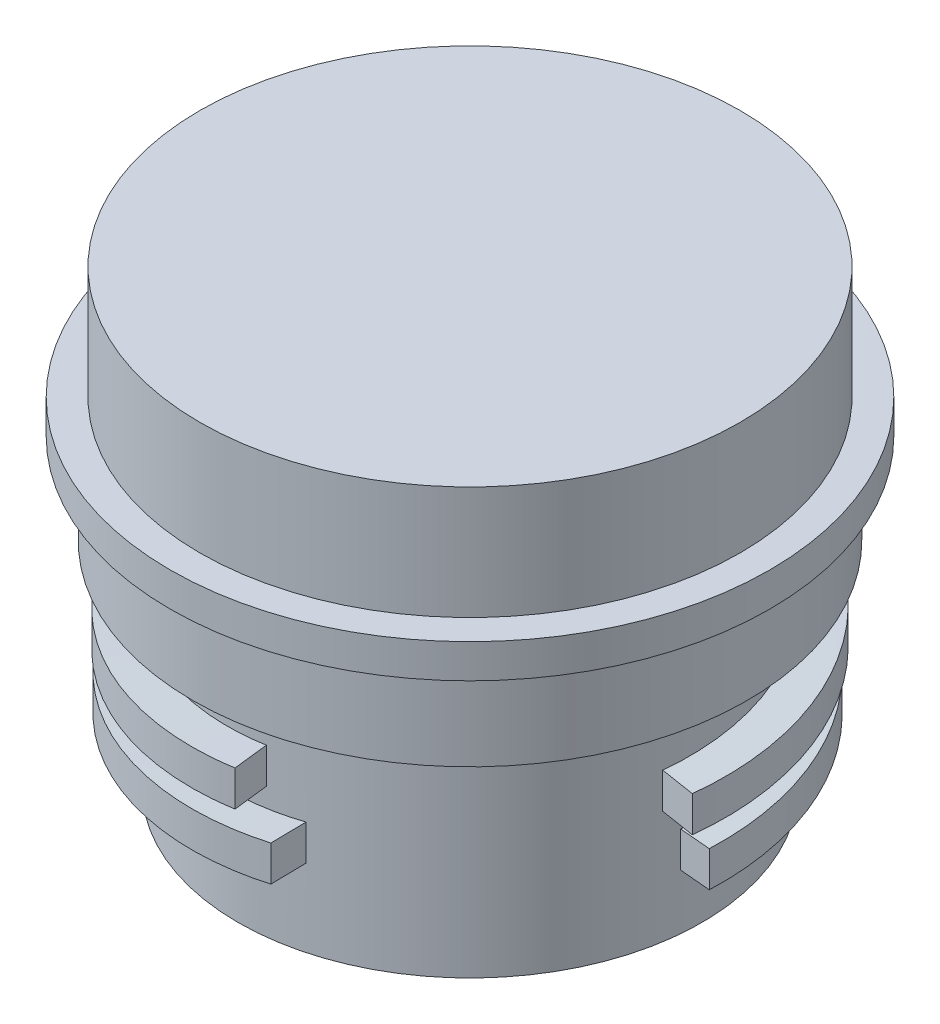
from build123d import *

# Parameters (mm, degrees)
SKETCH1_R           = 20.5
BOSS_EXTRUDE1_DEPTH = 19
SKETCH2_R           = 24.5
BOSS_EXTRUDE2_DEPTH = 8
SKETCH3_R           = 26.5
BOSS_EXTRUDE3_DEPTH = 3
SKETCH4_R           = 23.886443451
BOSS_EXTRUDE4_DEPTH = 10
SWEEP1_PITCH        = 6.35
SWEEP1_HEIGHT       = 1.9685
SWEEP1_RADIUS       = 20.5
SWEEP1_START_ANGLE  = -105
SKETCH10_W          = 6.049698943
SKETCH10_H          = 3.15
SWEEP2_PITCH        = 6.35
SWEEP2_HEIGHT       = 2.2225
SWEEP2_RADIUS       = 20.5
SWEEP2_START_ANGLE  = -111
SKETCH11_W          = 5.521256515
SKETCH11_H          = 3.15
SWEEP3_PITCH        = 6.35
SWEEP3_HEIGHT       = 2.2225
SWEEP3_RADIUS       = 20.5
SWEEP3_START_ANGLE  = 84.999942704
SKETCH18_W          = 6.3
SKETCH18_H          = 3.15
SWEEP4_PITCH        = 6.35
SWEEP4_HEIGHT       = 1.9685
SWEEP4_RADIUS       = 20.5
SWEEP4_START_ANGLE  = 80.999942704
SKETCH19_W          = 6.3
SKETCH19_H          = 3.15


with BuildPart() as part:
    # Sketch1 → Boss-Extrude1 (new body)
    with BuildSketch(Plane(origin=(0, 0, 0), x_dir=(1, 0, 0), z_dir=(0, 1, 0))):
        Circle(SKETCH1_R)
    extrude(amount=BOSS_EXTRUDE1_DEPTH)

    # Sketch2 → Boss-Extrude2 (add)
    with BuildSketch(Plane(origin=(0, 19, 0), x_dir=(1, 0, 0), z_dir=(0, 1, 0))):
        Circle(SKETCH2_R)
    extrude(amount=BOSS_EXTRUDE2_DEPTH)

    # Sketch3 → Boss-Extrude3 (add)
    with BuildSketch(Plane(origin=(0, 27, 0), x_dir=(1, 0, 0), z_dir=(0, 1, 0))):
        Circle(SKETCH3_R)
    extrude(amount=BOSS_EXTRUDE3_DEPTH)

    # Sketch4 → Boss-Extrude4 (add)
    with BuildSketch(Plane(origin=(0, 30, 0), x_dir=(1, 0, 0), z_dir=(0, 1, 0))):
        Circle(SKETCH4_R)
    extrude(amount=BOSS_EXTRUDE4_DEPTH)

    # Sweep1: sweep along a helix
    with BuildLine() as sweep1_path:
        add(Helix(SWEEP1_PITCH, SWEEP1_HEIGHT, SWEEP1_RADIUS, center=(0, 11.25, 0), direction=(0, 1, 0), mode=Mode.PRIVATE).rotate(Axis((0, 11.25, 0), (0, 1, 0)), SWEEP1_START_ANGLE))
    # Sketch10 → Sweep1 (sweep)
    with BuildSketch(Plane.XY):
        with Locations((-20.625150529, 11.420617779)):
            Rectangle(SKETCH10_W, SKETCH10_H)
    sweep(path=sweep1_path.line, is_frenet=True)

    # Sweep2: sweep along a helix
    with BuildLine() as sweep2_path:
        add(Helix(SWEEP2_PITCH, SWEEP2_HEIGHT, SWEEP2_RADIUS, center=(0, 6.25, 0), direction=(0, 1, 0), mode=Mode.PRIVATE).rotate(Axis((0, 6.25, 0), (0, 1, 0)), SWEEP2_START_ANGLE))
    # Sketch11 → Sweep2 (sweep)
    with BuildSketch(Plane.XY.offset(5)):
        with Locations((-20.28419045, 6.826925212)):
            Rectangle(SKETCH11_W, SKETCH11_H)
    sweep(path=sweep2_path.line, is_frenet=True)

    # Sweep3: sweep along a helix
    with BuildLine() as sweep3_path:
        add(Helix(SWEEP3_PITCH, SWEEP3_HEIGHT, SWEEP3_RADIUS, center=(0, 6.25, 0), direction=(0, 1, 0), mode=Mode.PRIVATE).rotate(Axis((0, 6.25, 0), (0, 1, 0)), SWEEP3_START_ANGLE))
    # Sketch18 → Sweep3 (sweep)
    with BuildSketch(Plane.XY):
        with Locations((20.122904995, 6.532252343)):
            Rectangle(SKETCH18_W, SKETCH18_H)
    sweep(path=sweep3_path.line, is_frenet=True)

    # Sweep4: sweep along a helix
    with BuildLine() as sweep4_path:
        add(Helix(SWEEP4_PITCH, SWEEP4_HEIGHT, SWEEP4_RADIUS, center=(0, 11.25, 0), direction=(0, 1, 0), mode=Mode.PRIVATE).rotate(Axis((0, 11.25, 0), (0, 1, 0)), SWEEP4_START_ANGLE))
    # Sketch19 → Sweep4 (sweep)
    with BuildSketch(Plane.XY):
        with Locations((20.5, 11.736280473)):
            Rectangle(SKETCH19_W, SKETCH19_H)
    sweep(path=sweep4_path.line, is_frenet=True)


solid = part.part
